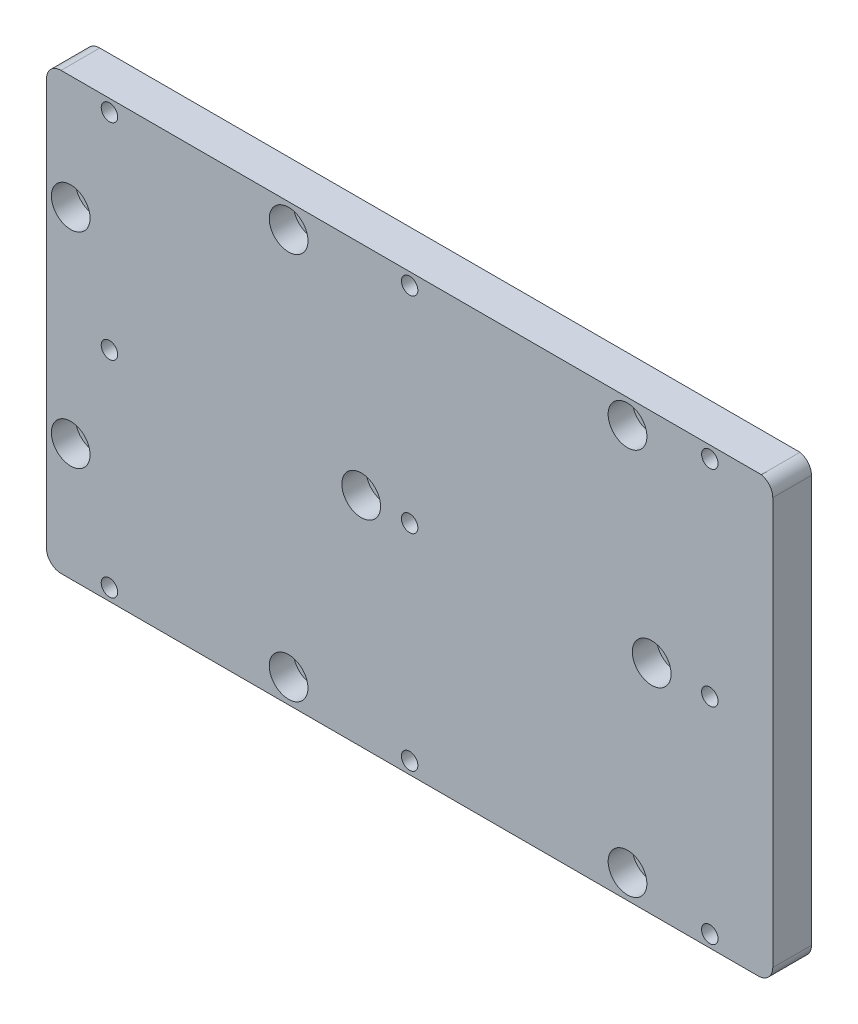
from build123d import *

# Parameters (mm, degrees)
ESQUISSE1_R             = 1.25
BOSS_EXTRU_1_DEPTH      = 8
TROU_TARAUD_M3_D        = 3.4
ESQUISSE4_R             = 1.6
ENL_V_MAT_EXTRU_1_DEPTH = 9
ESQUISSE5_R             = 4
ENL_V_MAT_EXTRU_2_DEPTH = 5


with BuildPart() as part:
    # Esquisse1 → Boss.-Extru.1 (new body)
    with BuildSketch(Plane.XY):
        with BuildLine():
            Line((2.96841177, 10.030192742), (146.96841177, 10.030192742))
            ThreePointArc((146.96841177, 10.030192742), (149.089732114, 10.908872398), (149.96841177, 13.030192742))
            Line((149.96841177, 13.030192742), (149.96841177, 97.09690847))
            ThreePointArc((149.96841177, 97.09690847), (149.301594422, 98.982712998), (147.597572626, 100.030192742))
            Line((147.597572626, 100.030192742), (2.96841177, 100.030192742))
            ThreePointArc((2.96841177, 100.030192742), (0.847091427, 99.151513085), (-0.03158823, 97.030192742))
            Line((-0.03158823, 97.030192742), (-0.03158823, 13.030192742))
            ThreePointArc((-0.03158823, 13.030192742), (0.847091427, 10.908872398), (2.96841177, 10.030192742))
        make_face()
        with Locations((12.96841177, 97.530192742)):
            Circle(ESQUISSE1_R, mode=Mode.SUBTRACT)
        with Locations((74.96841177, 97.530192742)):
            Circle(ESQUISSE1_R, mode=Mode.SUBTRACT)
        with Locations((136.96841177, 97.530192742)):
            Circle(ESQUISSE1_R, mode=Mode.SUBTRACT)
        with Locations((12.96841177, 55.030192742)):
            Circle(ESQUISSE1_R, mode=Mode.SUBTRACT)
        with Locations((74.96841177, 55.030192742)):
            Circle(ESQUISSE1_R, mode=Mode.SUBTRACT)
        with Locations((136.96841177, 55.030192742)):
            Circle(ESQUISSE1_R, mode=Mode.SUBTRACT)
        with Locations((136.96841177, 12.530192742)):
            Circle(ESQUISSE1_R, mode=Mode.SUBTRACT)
        with Locations((74.96841177, 12.530192742)):
            Circle(ESQUISSE1_R, mode=Mode.SUBTRACT)
        with Locations((12.96841177, 12.530192742)):
            Circle(ESQUISSE1_R, mode=Mode.SUBTRACT)
    extrude(amount=BOSS_EXTRU_1_DEPTH)

    # Trou taraudé M3 (through all)
    with Locations(Plane.XY.offset(8)):
        with Locations((12.96841177, 97.530192742), (12.96841177, 55.030192742), (12.96841177, 12.530192742), (74.96841177, 12.530192742), (74.96841177, 55.030192742), (74.96841177, 97.530192742), (136.96841177, 97.530192742), (136.96841177, 55.030192742), (136.96841177, 12.530192742)):
            Hole(TROU_TARAUD_M3_D / 2)

    # Esquisse4 → Enlèv. mat.-Extru.1 (cut, through all)
    with BuildSketch(Plane.XY.offset(8)):
        with Locations((119.96841177, 95.030192742)):
            Circle(ESQUISSE4_R)
        with Locations((49.96841177, 95.030192742)):
            Circle(ESQUISSE4_R)
        with Locations((4.96841177, 76.55605286)):
            Circle(ESQUISSE4_R)
        with Locations((4.96841177, 34.250278271)):
            Circle(ESQUISSE4_R)
        with Locations((49.96841177, 15.030192742)):
            Circle(ESQUISSE4_R)
        with Locations((119.96841177, 15.030192742)):
            Circle(ESQUISSE4_R)
        with Locations((64.96841177, 55.030192742)):
            Circle(ESQUISSE4_R)
        with Locations((124.96841177, 55.030192742)):
            Circle(ESQUISSE4_R)
    extrude(amount=-ENL_V_MAT_EXTRU_1_DEPTH, mode=Mode.SUBTRACT)

    # Esquisse5 → Enlèv. mat.-Extru.2 (cut)
    with BuildSketch(Plane.XY.offset(8)):
        with Locations((49.96841177, 95.030192742)):
            Circle(ESQUISSE5_R)
        with Locations((119.96841177, 95.030192742)):
            Circle(ESQUISSE5_R)
        with Locations((124.96841177, 55.030192742)):
            Circle(ESQUISSE5_R)
        with Locations((64.96841177, 55.030192742)):
            Circle(ESQUISSE5_R)
        with Locations((4.96841177, 76.55605286)):
            Circle(ESQUISSE5_R)
        with Locations((4.96841177, 34.250278271)):
            Circle(ESQUISSE5_R)
        with Locations((49.96841177, 15.030192742)):
            Circle(ESQUISSE5_R)
        with Locations((119.96841177, 15.030192742)):
            Circle(ESQUISSE5_R)
    extrude(amount=-ENL_V_MAT_EXTRU_2_DEPTH, mode=Mode.SUBTRACT)


solid = part.part
